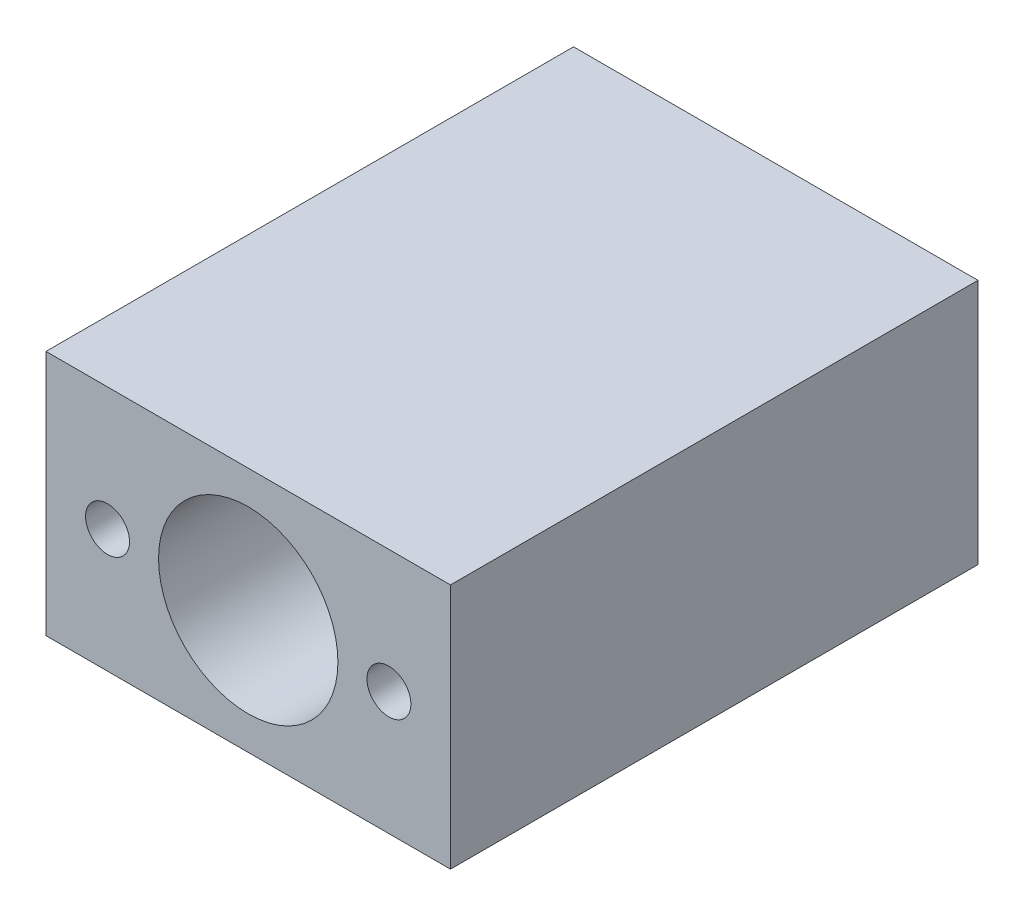
from build123d import *

# Parameters (mm, degrees)
CROQUIS1_W                                     = 23
CROQUIS1_H                                     = 14
CROQUIS1_R                                     = 5.1
SALIENTE_EXTRUIR1_DEPTH                        = 30
PERFORADOR_PARA_ROSCAR_PARA_MACHO_DE_ROS_D     = 2.5
PERFORADOR_PARA_ROSCAR_PARA_MACHO_DE_ROS_DEPTH = 12
PERFORADOR_PARA_ROSCAR_PARA_MACHO_DE_ROS_TIP   = 0.751075774


with BuildPart() as part:
    # Croquis1 → Saliente-Extruir1 (new body)
    with BuildSketch(Plane.XY):
        with Locations((11.5, 7)):
            Rectangle(CROQUIS1_W, CROQUIS1_H)
        with Locations((11.5, 7)):
            Circle(CROQUIS1_R, mode=Mode.SUBTRACT)
    extrude(amount=SALIENTE_EXTRUIR1_DEPTH)

    # Perforador para roscar para macho de roscar para M31
    with Locations(Plane.XY.offset(30)):
        with Locations((3.5, 7), (19.5, 7)):
            Hole(PERFORADOR_PARA_ROSCAR_PARA_MACHO_DE_ROS_D / 2, depth=PERFORADOR_PARA_ROSCAR_PARA_MACHO_DE_ROS_DEPTH)
            with Locations((0, 0, -(PERFORADOR_PARA_ROSCAR_PARA_MACHO_DE_ROS_DEPTH + PERFORADOR_PARA_ROSCAR_PARA_MACHO_DE_ROS_TIP / 2))):  # 118° drill point
                Cone(0, PERFORADOR_PARA_ROSCAR_PARA_MACHO_DE_ROS_D / 2, PERFORADOR_PARA_ROSCAR_PARA_MACHO_DE_ROS_TIP, mode=Mode.SUBTRACT)


solid = part.part
